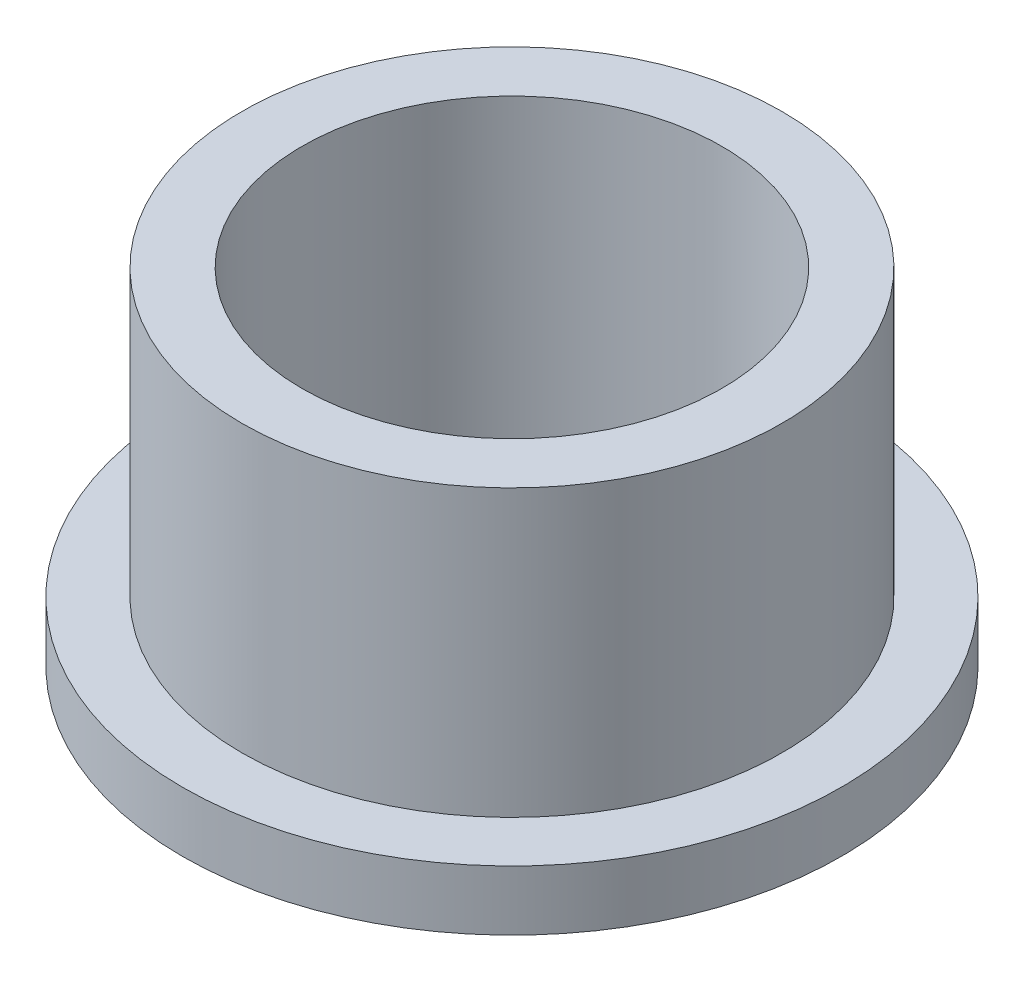
from build123d import *

# Parameters (mm, degrees)
SKETCH2_R           = 9.015
SKETCH2_R_2         = 7.005
BOSS_EXTRUDE1_DEPTH = 14
SKETCH3_R           = 11
SKETCH3_R_2         = 9.015
BOSS_EXTRUDE2_DEPTH = 2
CUT_EXTRUDE1_START  = -2.475
SKETCH4_R           = 9.015
CUT_EXTRUDE1_DEPTH  = 2.475


with BuildPart() as part:
    # Sketch2 → Boss-Extrude1 (new body)
    with BuildSketch(Plane(origin=(0, 0, 0), x_dir=(1, 0, 0), z_dir=(0, 1, 0))):
        Circle(SKETCH2_R)
        Circle(SKETCH2_R_2, mode=Mode.SUBTRACT)
    extrude(amount=BOSS_EXTRUDE1_DEPTH)

    # Sketch3 → Boss-Extrude2 (add)
    with BuildSketch(Plane(origin=(0, 0, 0), x_dir=(1, 0, 0), z_dir=(0, 1, 0))):
        Circle(SKETCH3_R)
        Circle(SKETCH3_R_2, mode=Mode.SUBTRACT)
    extrude(amount=BOSS_EXTRUDE2_DEPTH)

    # Sketch4 → Cut-Extrude1 (cut)
    with BuildSketch(Plane(origin=(0, 14, 0), x_dir=(1, 0, 0), z_dir=(0, 1, 0)).offset(CUT_EXTRUDE1_START)):
        Circle(SKETCH4_R)
    extrude(amount=CUT_EXTRUDE1_DEPTH, mode=Mode.SUBTRACT)


solid = part.part
